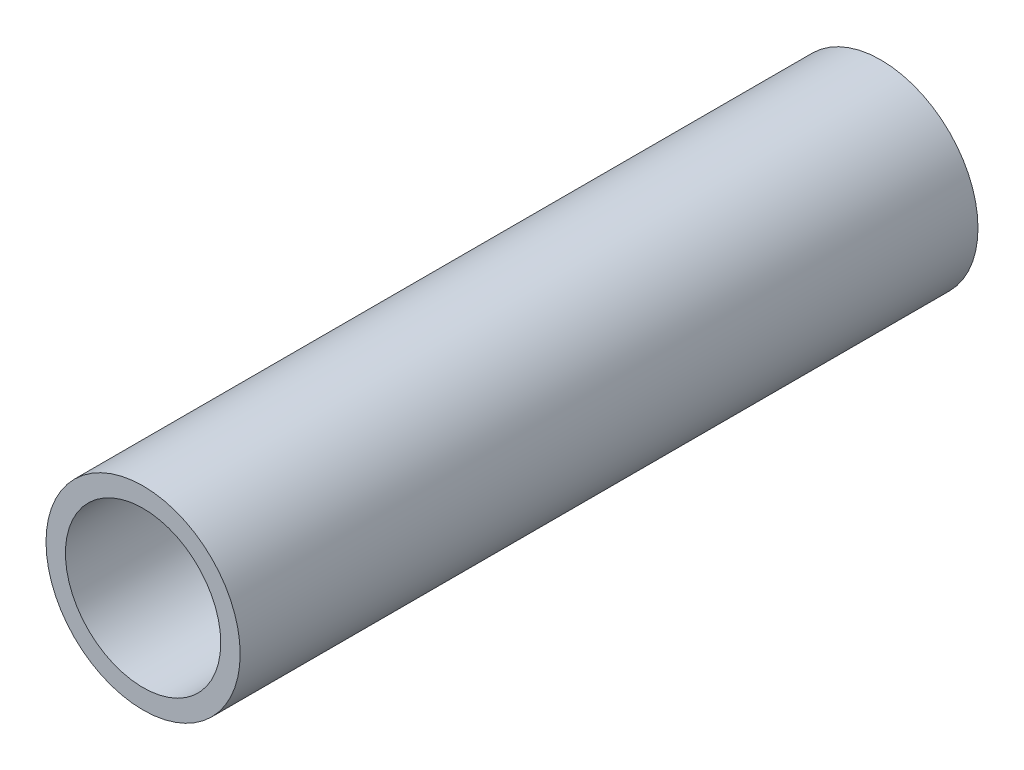
from build123d import *

# Parameters (mm, degrees)
SKETCH1_R           = 1.25
SKETCH1_R_2         = 1
BOSS_EXTRUDE1_DEPTH = 9.5


with BuildPart() as part:
    # Sketch1 → Boss-Extrude1 (new body)
    with BuildSketch(Plane.XY):
        Circle(SKETCH1_R)
        Circle(SKETCH1_R_2, mode=Mode.SUBTRACT)
    extrude(amount=BOSS_EXTRUDE1_DEPTH)


solid = part.part
